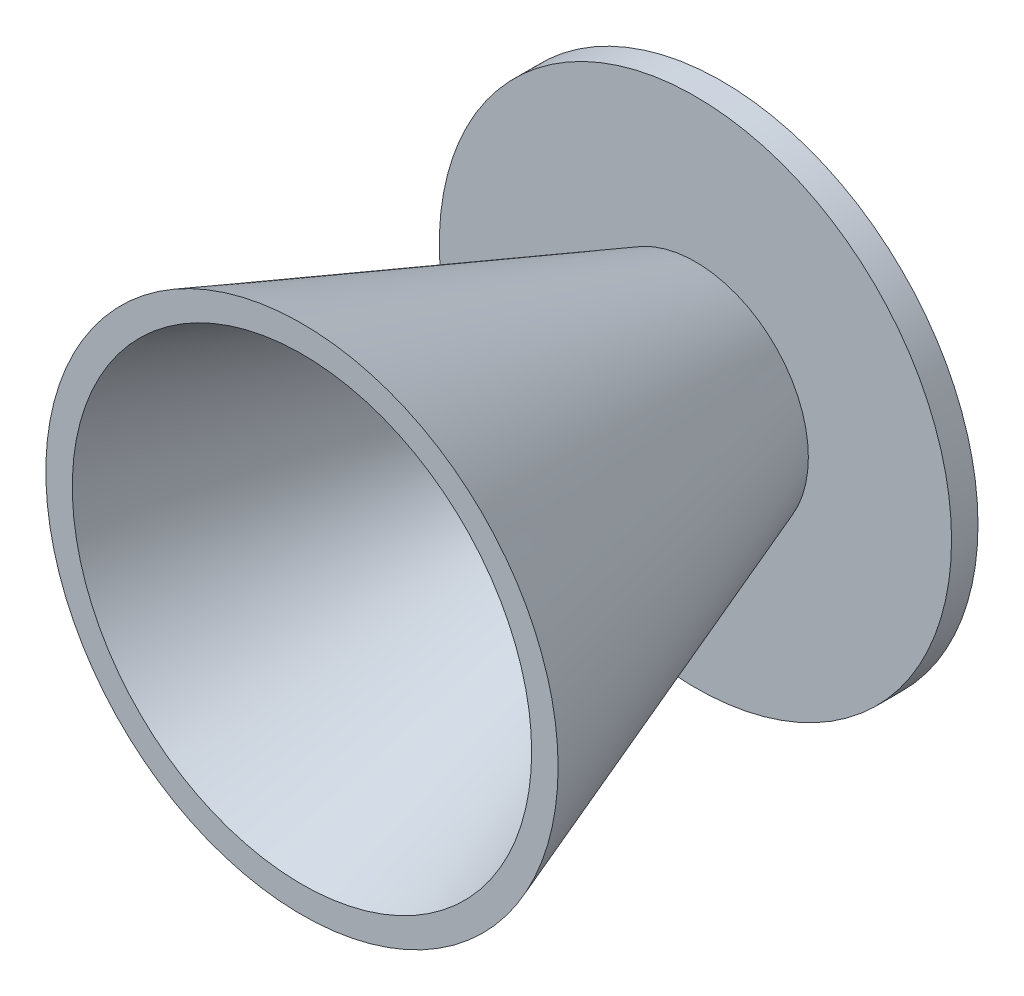
from build123d import *

# Parameters (mm, degrees)
CHAMFER1_SIZE  = 4.24981925
CHAMFER1_SIZE2 = 2.54


with BuildPart() as part:
    # Sketch1 → Revolve2 (revolve)
    with BuildSketch(Plane(origin=(0, 0, 0), x_dir=(0, 0, -1), z_dir=(1, 0, 0)), mode=Mode.PRIVATE) as revolve2_sk:
        Polygon((-1.6, 0), (-1.6, 5.231508424), (-25.4, 13.894), (-25.4, 15.494), (-1.6, 6.831508424), (-1.6, 15.494), (0, 15.494), (0, 0), align=None)
    revolve(revolve2_sk.sketch.rotate(Axis((0, 0, 1.6), (0, 0, -1)), 90), axis=Axis((0, 0, 1.6), (0, 0, -1)))  # turned: the seam where the file's is

    # Chamfer1
    chamfer1_edges = [part.edges().sort_by_distance(p)[0] for p in [
        (-5.231508424, 0, 1.6),
    ]]
    chamfer1_side = [part.faces().sort_by_distance(p)[0] for p in [
        (0, 0, 1.6),
    ]]
    chamfer(chamfer1_edges, length=CHAMFER1_SIZE, length2=CHAMFER1_SIZE2, reference=chamfer1_side[0])


solid = part.part
